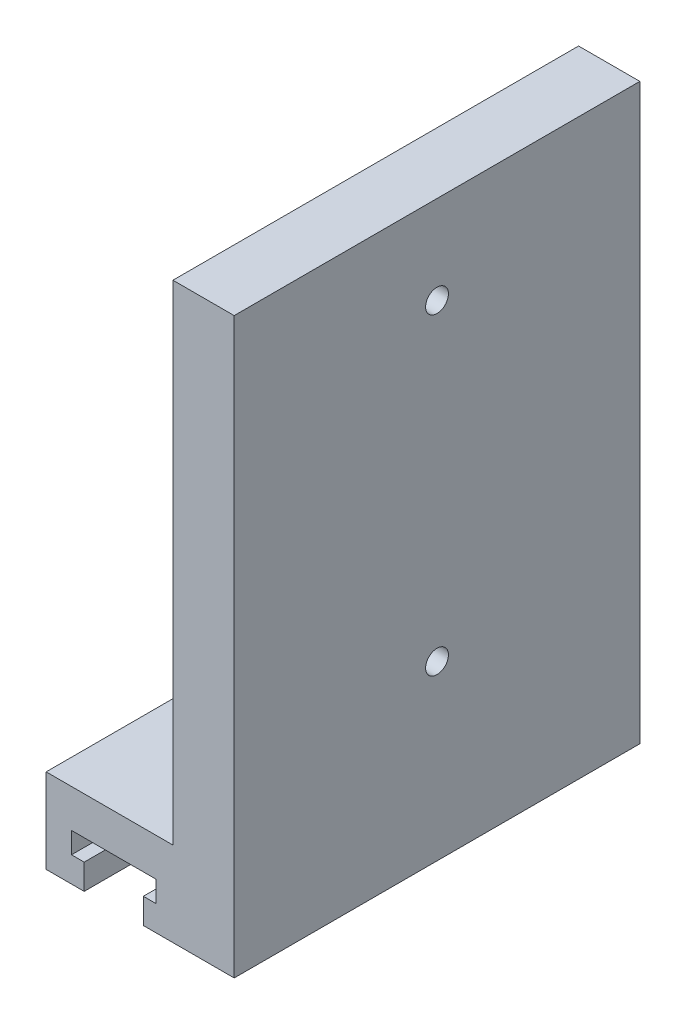
from build123d import *

# Parameters (mm, degrees)
BOSS_EXTRUDE1_DEPTH    = 48
M2_5_CLEARANCE_HOLE2_D = 2.7
M2_5_CLEARANCE_HOLE3_D = 2.7


with BuildPart() as part:
    # Sketch3 → Boss-Extrude1 (new body)
    with BuildSketch(Plane.XY.offset(10)):
        Polygon((-8, 13), (-3.5, 13), (-3.5, 16), (-5, 16), (-5, 18.5), (5, 18.5), (5, 16), (3.5, 16), (3.5, 13), (14.25, 13), (14.25, 80.88), (7, 80.88), (7, 23), (-8, 23), align=None)
    extrude(amount=-BOSS_EXTRUDE1_DEPTH)

    # M2.5 Clearance Hole2 (through all)
    with Locations(Plane(origin=(0, 23, 0), x_dir=(1, 0, 0), z_dir=(0, 1, 0))):
        with Locations((0, 14)):
            Hole(M2_5_CLEARANCE_HOLE2_D / 2)

    # M2.5 Clearance Hole3 (through all)
    with Locations(Plane.ZY.offset(-7)):
        with Locations((-14, 70.44), (-14, 33.44)):
            Hole(M2_5_CLEARANCE_HOLE3_D / 2)


solid = part.part
